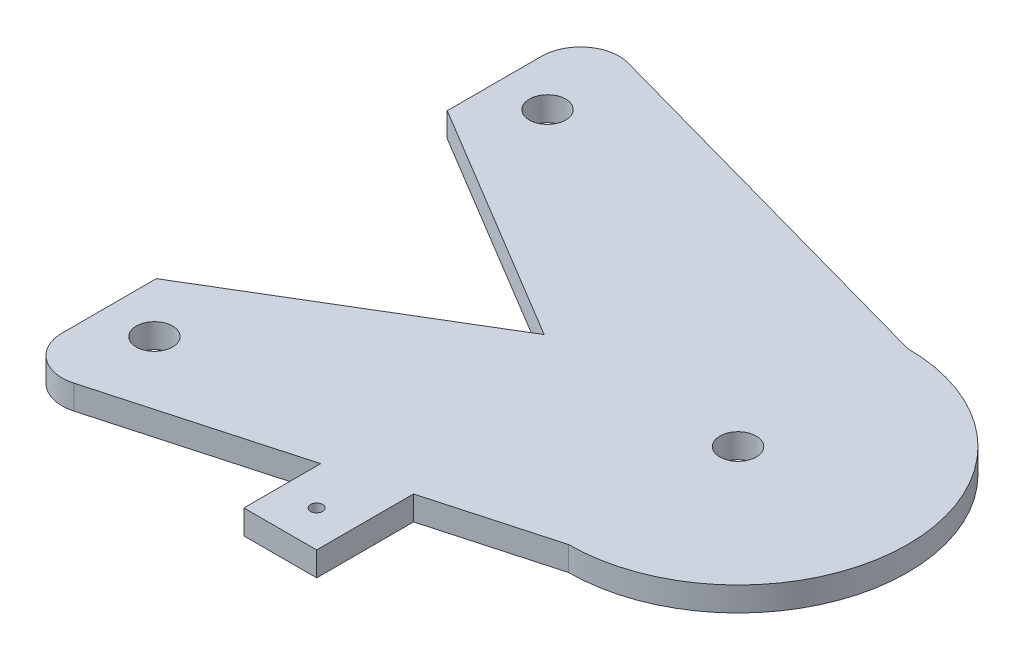
from build123d import *

# Parameters (mm, degrees)
SKETCH1_R           = 4.7625
SKETCH1_R_2         = 1.5875
BOSS_EXTRUDE1_DEPTH = 6.35


with BuildPart() as part:
    # Sketch1 → Boss-Extrude1 (new body)
    with BuildSketch(Plane(origin=(0, 0, 0), x_dir=(1, 0, 0), z_dir=(0, 1, 0))):
        with BuildLine():
            Line((-50.620738344, 72.622427318), (50.8, 44.45))
            ThreePointArc((50.8, 44.45), (95.25, 0), (50.8, -44.45))
            Line((50.8, -44.45), (19.05, -53.269444444))
            Line((19.05, -53.269444444), (19.05, -78.669444444))
            Line((19.05, -78.669444444), (0, -78.669444444))
            Line((0, -78.669444444), (0, -58.561111111))
            Line((0, -58.561111111), (-50.620738344, -72.622427318))
            ThreePointArc((-50.620738344, -72.622427318), (-59.488085132, -70.921759488), (-63.5, -62.833085356))
            Line((-63.5, -62.833085356), (-63.5, -38.1))
            Line((-63.5, -38.1), (0, 0))
            Line((0, 0), (-63.5, 38.1))
            Line((-63.5, 38.1), (-63.5, 62.833085356))
            ThreePointArc((-63.5, 62.833085356), (-59.488085132, 70.921759488), (-50.620738344, 72.622427318))
        make_face()
        with Locations((50.8, 0)):
            Circle(SKETCH1_R, mode=Mode.SUBTRACT)
        with Locations((-50.620738344, 51.497435162)):
            Circle(SKETCH1_R, mode=Mode.SUBTRACT)
        with Locations((-50.620738344, -51.497435162)):
            Circle(SKETCH1_R, mode=Mode.SUBTRACT)
        with Locations((9.525, -69.144444444)):
            Circle(SKETCH1_R_2, mode=Mode.SUBTRACT)
    extrude(amount=BOSS_EXTRUDE1_DEPTH)


solid = part.part
